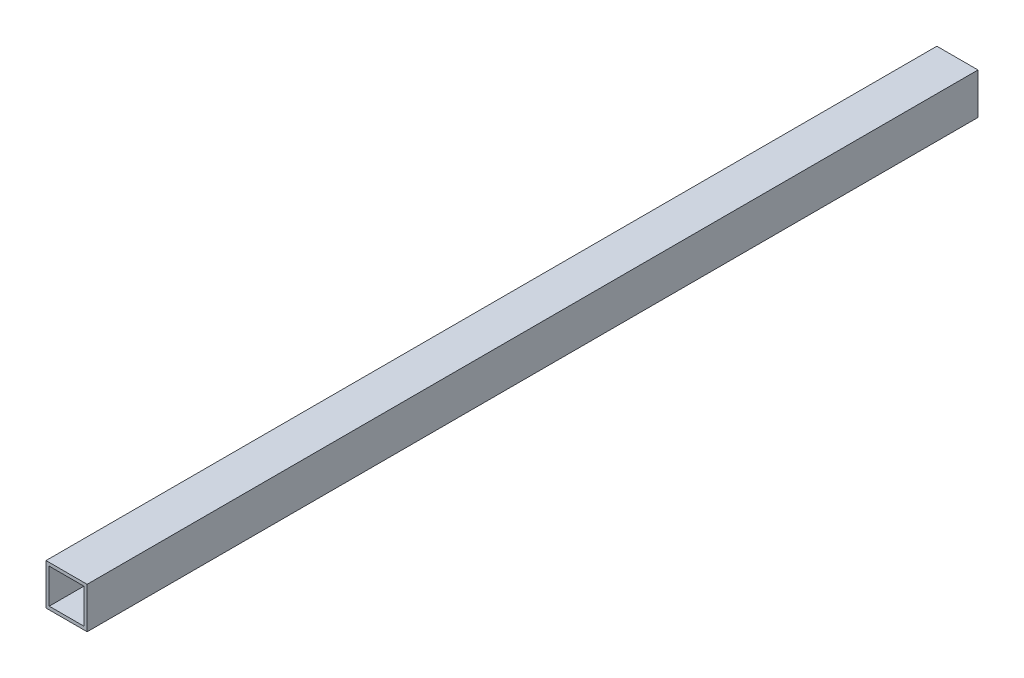
from build123d import *

# Parameters (mm, degrees)
SKETCH1_W           = 25.4
SKETCH1_H           = 25.4
SKETCH1_W_2         = 21.4
SKETCH1_H_2         = 21.4
BOSS_EXTRUDE1_DEPTH = 550


with BuildPart() as part:
    # Sketch1 → Boss-Extrude1 (new body)
    with BuildSketch(Plane.XY):
        Rectangle(SKETCH1_W, SKETCH1_H)
        Rectangle(SKETCH1_W_2, SKETCH1_H_2, mode=Mode.SUBTRACT)
    extrude(amount=BOSS_EXTRUDE1_DEPTH)


solid = part.part
